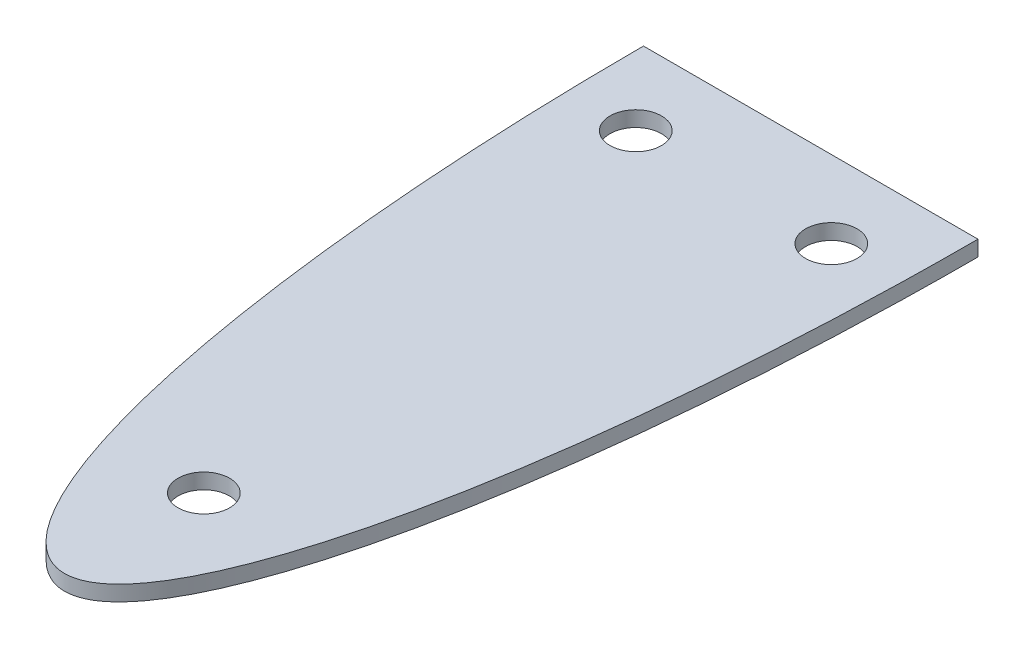
from build123d import *

# Parameters (mm, degrees)
BOSS_EXTRUDE1_DEPTH = 3
SKETCH3_R           = 5
CUT_EXTRUDE1_DEPTH  = 4.0000001


with BuildPart() as part:
    # Sketch2 → Boss-Extrude1 (new body)
    with BuildSketch(Plane(origin=(0, 0, 0), x_dir=(1, 0, 0), z_dir=(0, 1, 0))):
        with BuildLine():
            Line((-32.5, 0), (32.5, 0))
            add(Edge.make_bspline(
                [(-32.5, 0), (-32.5, -145), (0, -145), (32.5, -145), (32.5, 0)],
                knots=[1.570796327, 1.570796327, 1.570796327, 3.141592654, 3.141592654, 4.71238898, 4.71238898, 4.71238898], degree=2, weights=[1, 0.707106781, 1, 0.707106781, 1]))
        make_face()
    extrude(amount=BOSS_EXTRUDE1_DEPTH)

    # Sketch3 → Cut-Extrude1 (cut, through all)
    with BuildSketch(Plane(origin=(0, 3, 0), x_dir=(1, 0, 0), z_dir=(0, 1, 0))):
        with Locations((-19, -15)):
            Circle(SKETCH3_R)
        with Locations((0, -117.924839082)):
            Circle(SKETCH3_R)
        with Locations((19, -15)):
            Circle(SKETCH3_R)
    extrude(amount=-CUT_EXTRUDE1_DEPTH, mode=Mode.SUBTRACT)


solid = part.part
